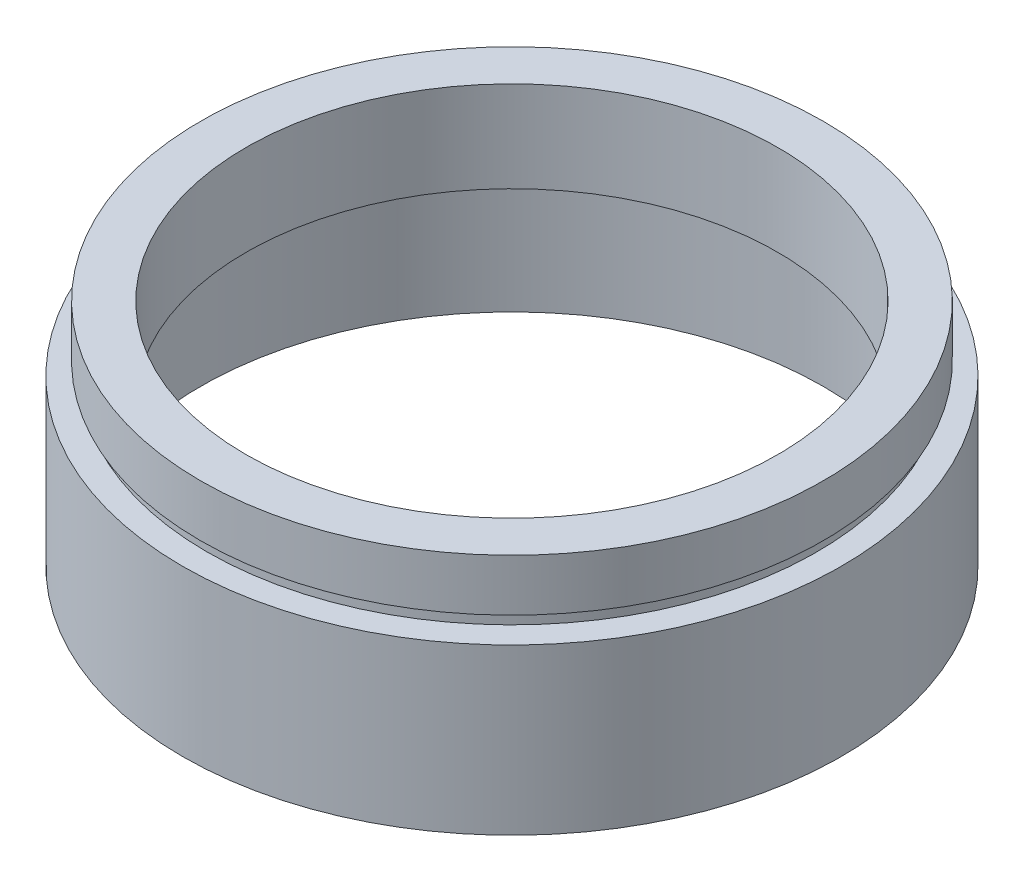
from build123d import *


with BuildPart() as part:
    # 草图1 → 旋转1 (revolve)
    with BuildSketch(Plane.XY, mode=Mode.PRIVATE) as revolve_1_sk:
        Polygon((20.5, 17.7), (24, 17.7), (24, 13.7), (23.5, 13.7), (23.5, 12.7), (25.4, 12.7), (25.4, 0), (24, 0), (24, 9.7), (24.1, 9.7), (24.1, 10.7), (20.5, 10.7), align=None)
    revolve(revolve_1_sk.sketch.rotate(Axis((0, 161.376166943, 0), (0, -1, 0)), 90), axis=Axis((0, 161.376166943, 0), (0, -1, 0)))  # turned: the seam where the file's is


solid = part.part
